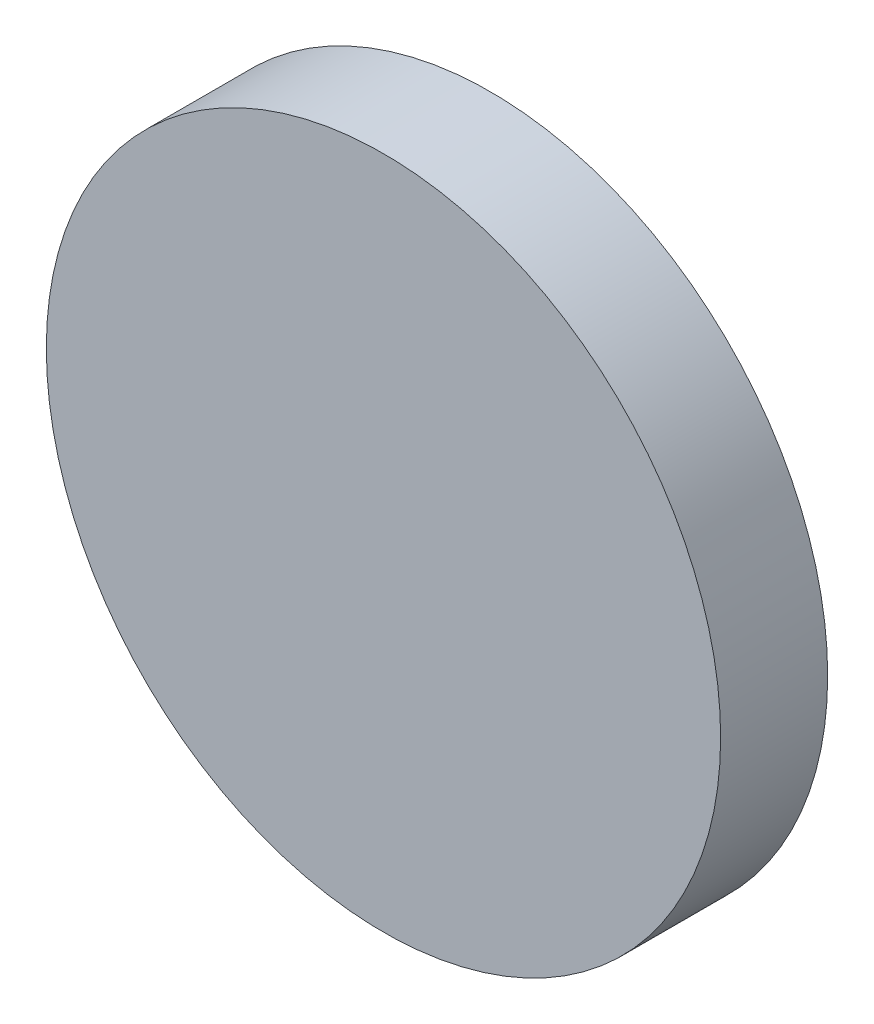
from build123d import *

# Parameters (mm, degrees)
SKETCH_1_R      = 3.15
EXTRUDE_1_DEPTH = 1


with BuildPart() as part:
    # 草图1 → 凸台-拉伸1 (new body)
    with BuildSketch(Plane.XY):
        Circle(SKETCH_1_R)
    extrude(amount=EXTRUDE_1_DEPTH)


solid = part.part
